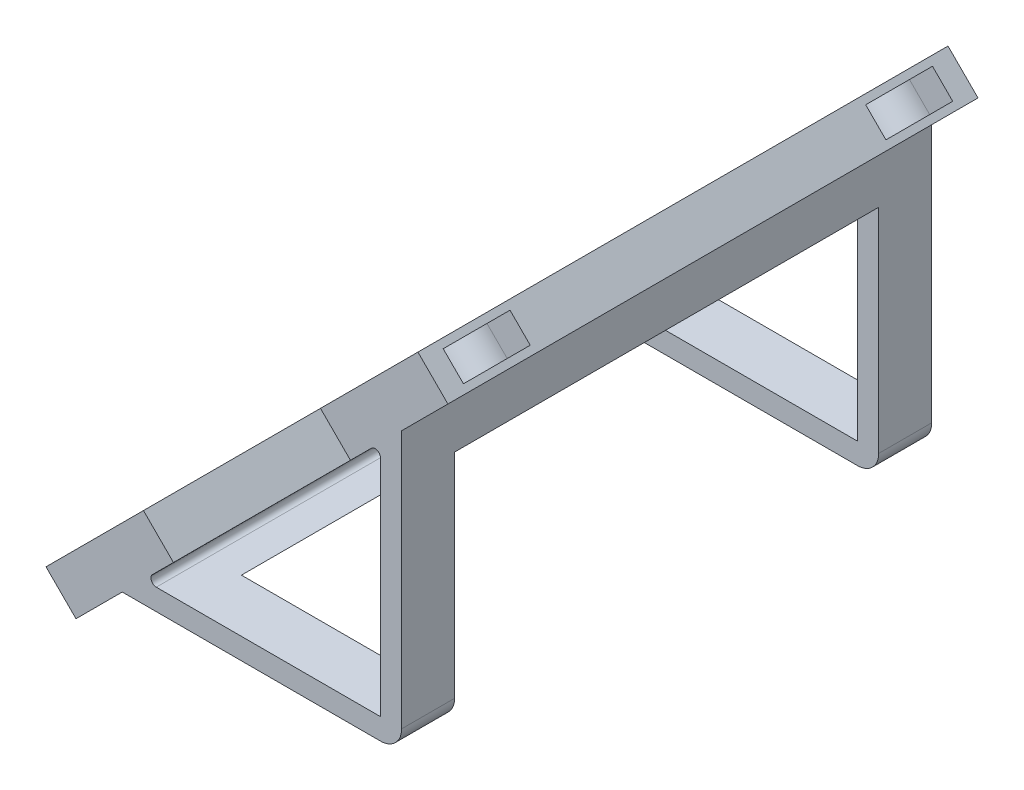
from build123d import *

# Parameters (mm, degrees)
BOSS_EXTRUDE1_DEPTH     = 50
CUT_EXTRUDE1_DEPTH      = 1.35
CUT_EXTRUDE1_DEPTH_BACK = 1.35
SKETCH3_W               = 40
SKETCH3_H               = 20
CUT_EXTRUDE2_DEPTH      = 52.612698372
FILLET1_R               = 0.5
FILLET2_R               = 2


with BuildPart() as part:
    # Sketch1 → Boss-Extrude1 (new body)
    with BuildSketch(Plane.XY):
        Polygon((-23.914213562, -1), (-1.560660172, -1), (-1.560660172, 21.353553391), (-4.389087297, 18.525126266), (-7.217514421, 21.353553391), (1.974873734, 30.545941546), (4.803300859, 27.717514421), (0.439339828, 23.353553391), (0.439339828, -3), (-25.914213562, -3), (-30.278174593, -7.363961031), (-33.106601718, -4.535533906), (-23.914213562, 4.656854249), (-21.085786438, 1.828427125), align=None)
    extrude(amount=-BOSS_EXTRUDE1_DEPTH)

    # Sketch2 → Cut-Extrude1 (cut, two sides)
    with BuildSketch(Plane(origin=(-12.871320344, 12.871320344, 0), x_dir=(0.707106781, 0.707106781, 0), z_dir=(-0.707106781, 0.707106781, 0))) as cut_extrude1_sk:
        with BuildLine():
            Line((19.925, 1.925), (22.995689014, 1.925))
            Line((22.995689014, 1.925), (22.995689014, 8.225))
            Line((22.995689014, 8.225), (19.925, 8.225))
            ThreePointArc((19.925, 8.225), (16.775, 5.075), (19.925, 1.925))
        make_face()
        with BuildLine():
            Line((19.925, 41.775), (22.995689014, 41.775))
            Line((22.995689014, 41.775), (22.995689014, 48.075))
            Line((22.995689014, 48.075), (19.925, 48.075))
            ThreePointArc((19.925, 48.075), (16.775, 44.925), (19.925, 41.775))
        make_face()
        with BuildLine():
            Line((-19.925, 1.925), (-26.617009358, 1.925))
            Line((-26.617009358, 1.925), (-26.617009358, 8.225))
            Line((-26.617009358, 8.225), (-19.925, 8.225))
            ThreePointArc((-19.925, 8.225), (-16.775, 5.075), (-19.925, 1.925))
        make_face()
        with BuildLine():
            Line((-19.925, 41.775), (-26.617009358, 41.775))
            Line((-26.617009358, 41.775), (-26.617009358, 48.075))
            Line((-26.617009358, 48.075), (-19.925, 48.075))
            ThreePointArc((-19.925, 48.075), (-16.775, 44.925), (-19.925, 41.775))
        make_face()
    extrude(amount=CUT_EXTRUDE1_DEPTH, mode=Mode.SUBTRACT)
    extrude(cut_extrude1_sk.sketch, amount=-CUT_EXTRUDE1_DEPTH_BACK, mode=Mode.SUBTRACT)

    # Sketch3 → Cut-Extrude2 (cut, through all)
    with BuildSketch(Plane(origin=(16.26040764, 16.26040764, 0), x_dir=(0, 0, -1), z_dir=(0.707106781, 0.707106781, 0))):
        with Locations((25, 3.202795796)):
            Rectangle(SKETCH3_W, SKETCH3_H)
    extrude(amount=-CUT_EXTRUDE2_DEPTH, mode=Mode.SUBTRACT)

    # Fillet1
    fillet1_edges = [part.edges().sort_by_distance(p)[0] for p in [
        (-1.560660172, 21.353553391, -25),
        (-23.914213562, -1, -25),
    ]]
    fillet(fillet1_edges, radius=FILLET1_R)

    # Fillet2
    fillet2_edges = [part.edges().sort_by_distance(p)[0] for p in [
        (0.439339828, -3, -47.5),
        (0.439339828, -3, -2.5),
    ]]
    fillet(fillet2_edges, radius=FILLET2_R)


solid = part.part
